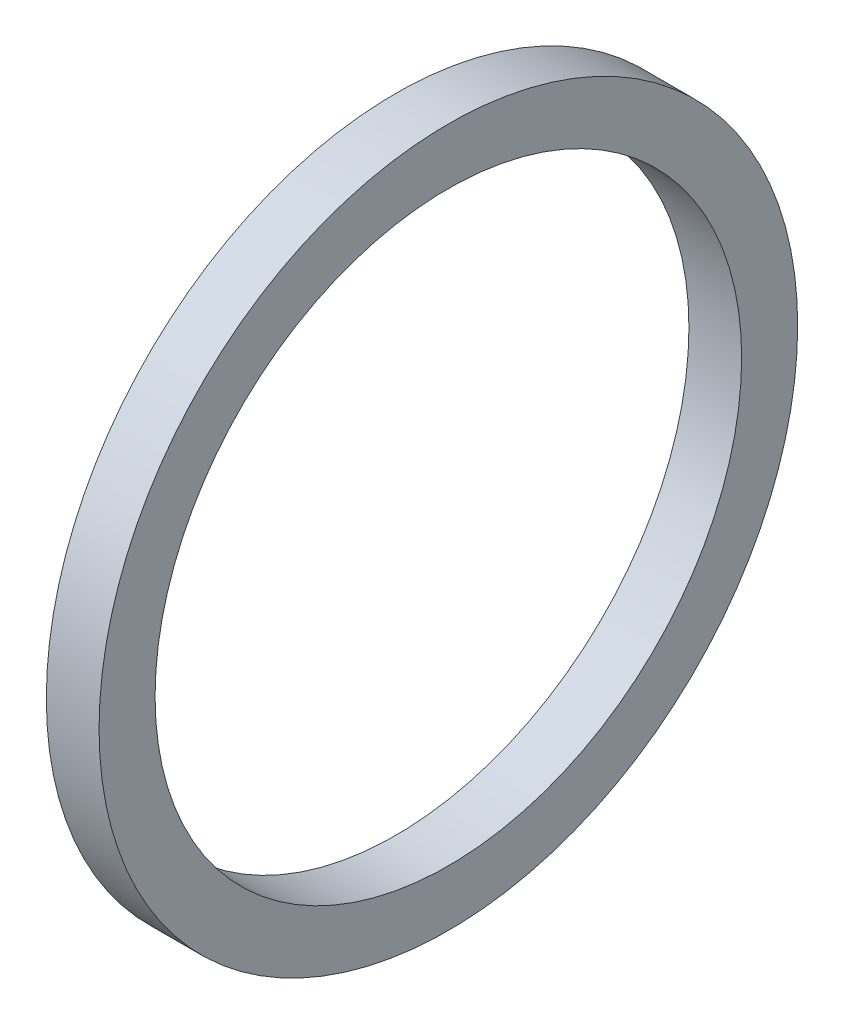
from build123d import *

# Parameters (mm, degrees)
SKETCH1_W = 2.032
SKETCH1_H = 2.159


with BuildPart() as part:
    # Sketch1 → Revolve1 (revolve)
    with BuildSketch(Plane.XY, mode=Mode.PRIVATE) as revolve1_sk:
        with Locations((1.016, -12.3825)):
            Rectangle(SKETCH1_W, SKETCH1_H)
    revolve(revolve1_sk.sketch.rotate(Axis((-43.716580756, 0, 0), (1, 0, 0)), 270), axis=Axis((-43.716580756, 0, 0), (1, 0, 0)))  # turned: the seam where the file's is


solid = part.part
